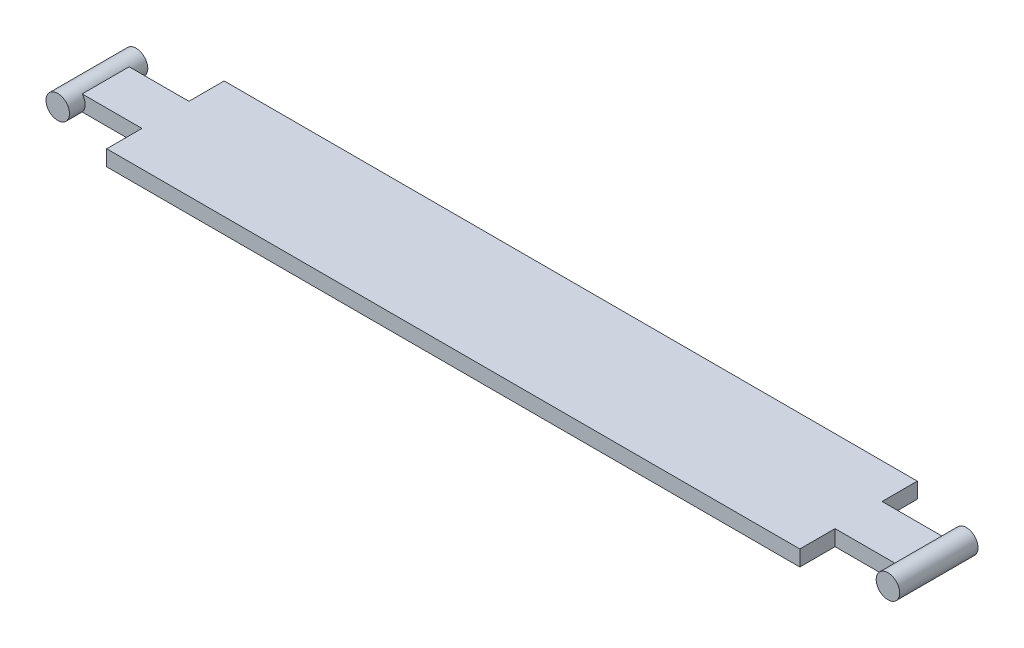
from build123d import *

# Parameters (mm, degrees)
EXTRUDE_1_DEPTH = 2
SKETCH_2_R      = 1.5
EXTRUDE_2_DEPTH = 5


with BuildPart() as part:
    # 草图1 → 凸台-拉伸1 (new body)
    with BuildSketch(Plane(origin=(0, 0, 0), x_dir=(1, 0, 0), z_dir=(0, 1, 0))):
        Polygon((44.25, 7.5), (-44.25, 7.5), (-44.25, 3), (-53, 3), (-53, -3), (-44.25, -3), (-44.25, -7.5), (44.25, -7.5), (44.25, -3), (53, -3), (53, 3), (44.25, 3), align=None)
    extrude(amount=EXTRUDE_1_DEPTH)

    # 草图2 → 凸台-拉伸2 (add, symmetric)
    with BuildSketch(Plane.XY):
        with Locations((-53, 1)):
            Circle(SKETCH_2_R)
        with Locations((53, 1)):
            Circle(SKETCH_2_R)
    extrude(amount=EXTRUDE_2_DEPTH, both=True)


solid = part.part
